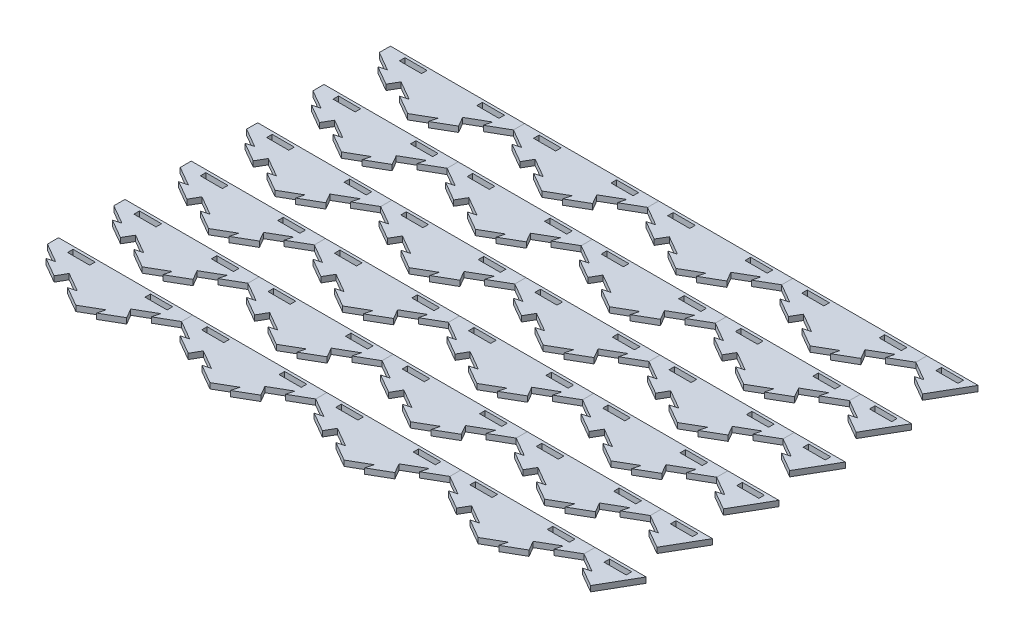
from build123d import *

# Parameters (mm, degrees)
BOSS_EXTRUDE1_DEPTH = 6.35
CUT_EXTRUDE4_DEPTH  = 155.110195964
BOSS_EXTRUDE4_DEPTH = 6.35
CIRPATTERN1_COUNT   = 2
CIRPATTERN1_ANGLE   = 60
SKETCH12_W          = 153.979316792
SKETCH12_H          = 120.65
CUT_EXTRUDE5_DEPTH  = 155.110195964
SKETCH13_W          = 25.4
SKETCH13_H          = 6.35
CUT_EXTRUDE6_DEPTH  = 90.126497182
LPATTERN1_COUNT     = 5
LPATTERN1_PITCH     = 153.979316882
LPATTERN1_2_COUNT   = 2
LPATTERN1_2_PITCH   = 153.979316882
SKETCH14_W          = 25.4
SKETCH14_H          = 6.35
SKETCH14_W_2        = 76.989658396
SKETCH14_H_2        = 57.15
CUT_EXTRUDE7_DEPTH  = 695.360232872
SKETCH15_W          = 58.658787349
SKETCH15_H          = 29.425738686
CUT_EXTRUDE8_DEPTH  = 600.270912242
LPATTERN2_COUNT     = 6
LPATTERN2_PITCH     = 76.2


with BuildPart() as part:
    # Sketch1 → Boss-Extrude1 (new body)
    with BuildSketch(Plane(origin=(0, 0, 0), x_dir=(1, 0, 0), z_dir=(0, 1, 0))):
        Polygon((-76.989658396, 0), (0, -44.45), (76.989658396, 0), (76.989658396, 88.9), (0, 133.35), (-76.989658396, 88.9), align=None)
    extrude(amount=-BOSS_EXTRUDE1_DEPTH)

    # Sketch10 → Cut-Extrude4 (cut, through all)
    with BuildSketch(Plane(origin=(0, 0, 0), x_dir=(1, 0, 0), z_dir=(0, 1, 0))):
        Polygon((-21.997045256, -31.75), (-13.322783942, -29.425738686), (-35.319829198, -16.725738686), (-38.494829198, -22.225), align=None)
    cut_extrude4 = extrude(amount=-CUT_EXTRUDE4_DEPTH, mode=Mode.SUBTRACT)

    # Sketch11 → Boss-Extrude4 (add)
    with BuildSketch(Plane(origin=(0, 0, 0), x_dir=(1, 0, 0), z_dir=(0, 1, 0))):
        Polygon((-38.494829198, -22.225), (-41.669829198, -27.724261314), (-63.666874454, -15.024261314), (-54.99261314, -12.7), align=None)
    boss_extrude4 = extrude(amount=-BOSS_EXTRUDE4_DEPTH)

    # CirPattern1: Cut-Extrude4, Boss-Extrude4 ×2 about axis
    cirpattern1_axis = Axis((0, 0, -44.45), (0, 1, 0))
    add([cut_extrude4.rotate(cirpattern1_axis, i * CIRPATTERN1_ANGLE / (CIRPATTERN1_COUNT - 1)) for i in range(1, CIRPATTERN1_COUNT)], mode=Mode.SUBTRACT)
    add([boss_extrude4.rotate(cirpattern1_axis, i * CIRPATTERN1_ANGLE / (CIRPATTERN1_COUNT - 1)) for i in range(1, CIRPATTERN1_COUNT)])

    # Sketch12 → Cut-Extrude5 (cut, through all)
    with BuildSketch(Plane(origin=(0, 0, 0), x_dir=(1, 0, 0), z_dir=(0, 1, 0))):
        with Locations((0, 73.025)):
            Rectangle(SKETCH12_W, SKETCH12_H)
    extrude(amount=-CUT_EXTRUDE5_DEPTH, mode=Mode.SUBTRACT)

    # Sketch13 → Cut-Extrude6 (cut, through all)
    with BuildSketch(Plane(origin=(0, 0, 0), x_dir=(1, 0, 0), z_dir=(0, 1, 0))):
        with Locations((-44.45, 6.35)):
            Rectangle(SKETCH13_W, SKETCH13_H)
        with Locations((44.45, 6.35)):
            Rectangle(SKETCH13_W, SKETCH13_H)
    extrude(amount=-CUT_EXTRUDE6_DEPTH, mode=Mode.SUBTRACT)


with BuildPart() as lpattern1_1:
    # LPattern1: pattern copy
    add(part.part.moved(Location(Vector(1, 0, 0) * (1 * LPATTERN1_PITCH))))


with BuildPart() as lpattern1_2:
    # LPattern1: pattern copy
    add(part.part.moved(Location(Vector(1, 0, 0) * (2 * LPATTERN1_PITCH))))


with BuildPart() as lpattern1_3:
    # LPattern1: pattern copy
    add(part.part.moved(Location(Vector(1, 0, 0) * (3 * LPATTERN1_PITCH))))


with BuildPart() as lpattern1_4:
    # LPattern1: pattern copy
    add(part.part.moved(Location(Vector(1, 0, 0) * (4 * LPATTERN1_PITCH))))


with BuildPart() as lpattern1_2_1:
    # LPattern1 2: pattern copy
    add(part.part.moved(Location(Vector(-1, 0, 0) * (1 * LPATTERN1_2_PITCH))))


with BuildPart() as cut_extrude7_tool:
    # Sketch14 → Cut-Extrude7 (new, through all)
    # profile 1 of 4: a face of its own
    with BuildSketch(Plane(origin=(0, 0, 0), x_dir=(1, 0, 0), z_dir=(0, 1, 0))):
        Polygon((-134.30653294, -40.424261314), (-153.979316882, -44.45), (-153.979316882, 12.7), (-135.648445835, 12.7), (-112.309487684, -27.724261314), align=None)
    # profile 2 of 4: a face of its own
    with BuildSketch(Plane(origin=(0, 0, 0), x_dir=(1, 0, 0), z_dir=(0, 1, 0))):
        Polygon((593.920222272, -31.75), (615.917267528, -44.45), (615.917267528, 12.7), (597.586396481, 12.7), (580.59743833, -16.725738686), (602.594483586, -29.425738686), align=None)
    # profile 3 of 4: a face of its own
    with BuildSketch(Plane(origin=(0, 0, 0), x_dir=(1, 0, 0), z_dir=(0, 1, 0))):
        Polygon((615.917267528, 12.7), (615.917267528, -44.45), (637.914312784, -31.75), (635.59005147, -40.424261314), (657.587096726, -27.724261314), (651.237096726, -16.725738686), (673.234141982, -4.025738686), (670.909880668, -12.7), (692.906925924, 0), (692.906925924, 12.7), align=None)
        with Locations((660.367267528, 6.35)):
            Rectangle(SKETCH14_W, SKETCH14_H, mode=Mode.SUBTRACT)
    # profile 4 of 4: a face of its own
    with BuildSketch(Plane(origin=(0, 0, 0), x_dir=(1, 0, 0), z_dir=(0, 1, 0))):
        with Locations((-192.47414608, -15.875)):
            Rectangle(SKETCH14_W_2, SKETCH14_H_2)
    extrude(amount=-CUT_EXTRUDE7_DEPTH)


with BuildPart() as lpattern1_4_1:
    add(lpattern1_4.part)

    # Cut-Extrude7: cut by cut_extrude7_tool
    add(cut_extrude7_tool.part, mode=Mode.SUBTRACT)


with BuildPart() as lpattern1_2_1_1:
    add(lpattern1_2_1.part)

    # Cut-Extrude7: cut by cut_extrude7_tool
    add(cut_extrude7_tool.part, mode=Mode.SUBTRACT)

    # Sketch15 → Cut-Extrude8 (cut, through all)
    with BuildSketch(Plane(origin=(0, 0, 0), x_dir=(1, 0, 0), z_dir=(0, 1, 0))):
        with Locations((-106.319052161, -2.012869343)):
            Rectangle(SKETCH15_W, SKETCH15_H)
    extrude(amount=-CUT_EXTRUDE8_DEPTH, mode=Mode.SUBTRACT)


with BuildPart() as lpattern2_1:
    # LPattern2: pattern copy
    add(lpattern1_4_1.part.moved(Location(Vector(0, 0, 1) * (1 * LPATTERN2_PITCH))))


with BuildPart() as lpattern2_2:
    # LPattern2: pattern copy
    add(lpattern1_4_1.part.moved(Location(Vector(0, 0, 1) * (2 * LPATTERN2_PITCH))))


with BuildPart() as lpattern2_3:
    # LPattern2: pattern copy
    add(lpattern1_4_1.part.moved(Location(Vector(0, 0, 1) * (3 * LPATTERN2_PITCH))))


with BuildPart() as lpattern2_4:
    # LPattern2: pattern copy
    add(lpattern1_4_1.part.moved(Location(Vector(0, 0, 1) * (4 * LPATTERN2_PITCH))))


with BuildPart() as lpattern2_5:
    # LPattern2: pattern copy
    add(lpattern1_4_1.part.moved(Location(Vector(0, 0, 1) * (5 * LPATTERN2_PITCH))))


with BuildPart() as lpattern2_6:
    # LPattern2: pattern copy
    add(lpattern1_3.part.moved(Location(Vector(0, 0, 1) * (1 * LPATTERN2_PITCH))))


with BuildPart() as lpattern2_7:
    # LPattern2: pattern copy
    add(lpattern1_3.part.moved(Location(Vector(0, 0, 1) * (2 * LPATTERN2_PITCH))))


with BuildPart() as lpattern2_8:
    # LPattern2: pattern copy
    add(lpattern1_3.part.moved(Location(Vector(0, 0, 1) * (3 * LPATTERN2_PITCH))))


with BuildPart() as lpattern2_9:
    # LPattern2: pattern copy
    add(lpattern1_3.part.moved(Location(Vector(0, 0, 1) * (4 * LPATTERN2_PITCH))))


with BuildPart() as lpattern2_10:
    # LPattern2: pattern copy
    add(lpattern1_3.part.moved(Location(Vector(0, 0, 1) * (5 * LPATTERN2_PITCH))))


with BuildPart() as lpattern2_11:
    # LPattern2: pattern copy
    add(lpattern1_2.part.moved(Location(Vector(0, 0, 1) * (1 * LPATTERN2_PITCH))))


with BuildPart() as lpattern2_12:
    # LPattern2: pattern copy
    add(lpattern1_2.part.moved(Location(Vector(0, 0, 1) * (2 * LPATTERN2_PITCH))))


with BuildPart() as lpattern2_13:
    # LPattern2: pattern copy
    add(lpattern1_2.part.moved(Location(Vector(0, 0, 1) * (3 * LPATTERN2_PITCH))))


with BuildPart() as lpattern2_14:
    # LPattern2: pattern copy
    add(lpattern1_2.part.moved(Location(Vector(0, 0, 1) * (4 * LPATTERN2_PITCH))))


with BuildPart() as lpattern2_15:
    # LPattern2: pattern copy
    add(lpattern1_2.part.moved(Location(Vector(0, 0, 1) * (5 * LPATTERN2_PITCH))))


with BuildPart() as lpattern2_16:
    # LPattern2: pattern copy
    add(lpattern1_1.part.moved(Location(Vector(0, 0, 1) * (1 * LPATTERN2_PITCH))))


with BuildPart() as lpattern2_17:
    # LPattern2: pattern copy
    add(lpattern1_1.part.moved(Location(Vector(0, 0, 1) * (2 * LPATTERN2_PITCH))))


with BuildPart() as lpattern2_18:
    # LPattern2: pattern copy
    add(lpattern1_1.part.moved(Location(Vector(0, 0, 1) * (3 * LPATTERN2_PITCH))))


with BuildPart() as lpattern2_19:
    # LPattern2: pattern copy
    add(lpattern1_1.part.moved(Location(Vector(0, 0, 1) * (4 * LPATTERN2_PITCH))))


with BuildPart() as lpattern2_20:
    # LPattern2: pattern copy
    add(lpattern1_1.part.moved(Location(Vector(0, 0, 1) * (5 * LPATTERN2_PITCH))))


with BuildPart() as lpattern2_21:
    # LPattern2: pattern copy
    add(part.part.moved(Location(Vector(0, 0, 1) * (1 * LPATTERN2_PITCH))))


with BuildPart() as lpattern2_22:
    # LPattern2: pattern copy
    add(part.part.moved(Location(Vector(0, 0, 1) * (2 * LPATTERN2_PITCH))))


with BuildPart() as lpattern2_23:
    # LPattern2: pattern copy
    add(part.part.moved(Location(Vector(0, 0, 1) * (3 * LPATTERN2_PITCH))))


with BuildPart() as lpattern2_24:
    # LPattern2: pattern copy
    add(part.part.moved(Location(Vector(0, 0, 1) * (4 * LPATTERN2_PITCH))))


with BuildPart() as lpattern2_25:
    # LPattern2: pattern copy
    add(part.part.moved(Location(Vector(0, 0, 1) * (5 * LPATTERN2_PITCH))))


solid = Compound([part.part, lpattern1_1.part, lpattern1_2.part, lpattern1_3.part, lpattern1_4_1.part, lpattern2_1.part, lpattern2_2.part, lpattern2_3.part, lpattern2_4.part, lpattern2_5.part, lpattern2_6.part, lpattern2_7.part, lpattern2_8.part, lpattern2_9.part, lpattern2_10.part, lpattern2_11.part, lpattern2_12.part, lpattern2_13.part, lpattern2_14.part, lpattern2_15.part, lpattern2_16.part, lpattern2_17.part, lpattern2_18.part, lpattern2_19.part, lpattern2_20.part, lpattern2_21.part, lpattern2_22.part, lpattern2_23.part, lpattern2_24.part, lpattern2_25.part])
